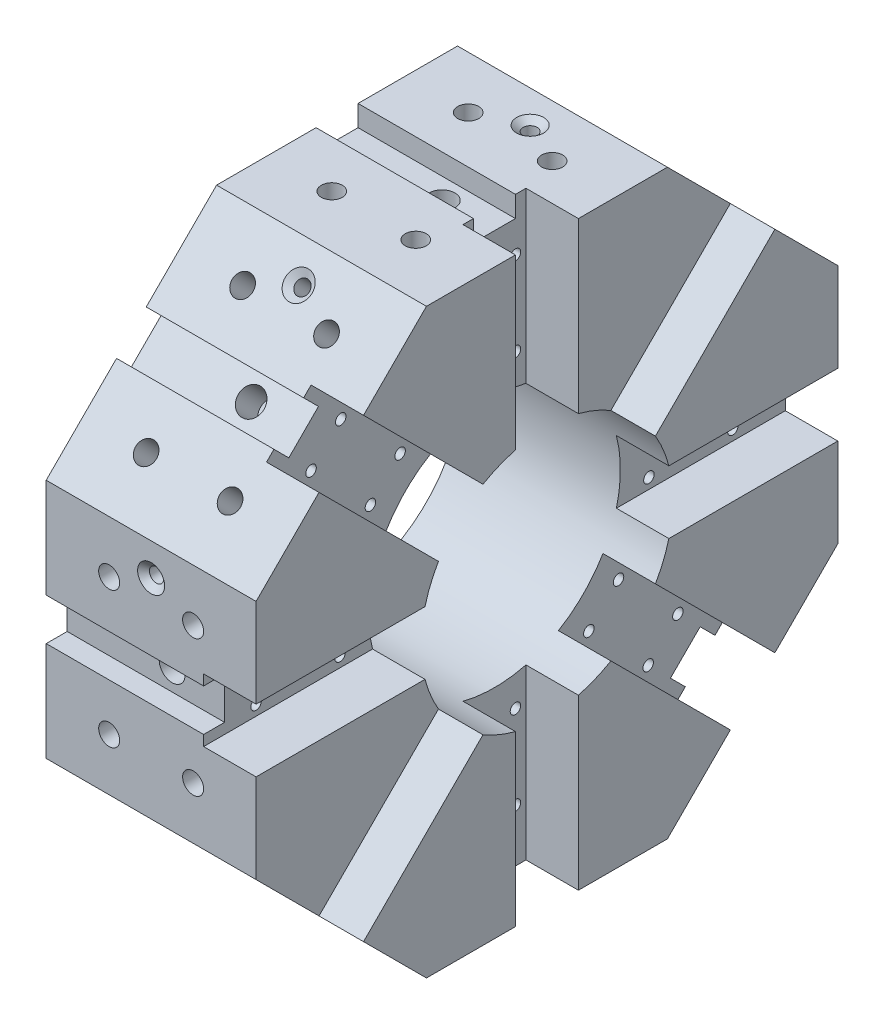
from build123d import *

# Parameters (mm, degrees)
SKETCH_2_R               = 60
EXTRUDE_1_DEPTH          = 100
CUT_EXTRUDE_START        = -80.48718
SKETCH_4_W               = 25
SKETCH_4_H               = 30
CUT_EXTRUDE_1_DEPTH      = 80.48718
SKETCH_6_W               = 20
SKETCH_6_H               = 10
CUT_EXTRUDE_2_DEPTH      = 75
SKETCH_7_R               = 5
CUT_EXTRUDE_3_DEPTH      = 20
SKETCH_10_R              = 2.5
CUT_EXTRUDE_4_DEPTH      = 10
PATTERN_CIRCULAR_1_COUNT = 8


with BuildPart() as part:
    # 草图2 → 凸台-拉伸1 (new body)
    with BuildSketch(Plane(origin=(0, 0, 0), x_dir=(0, 0, -1), z_dir=(1, 0, 0))):
        Polygon((-57.402514855, 138.581929877), (-138.581929877, 57.402514855), (-138.581929877, -57.402514855), (-57.402514855, -138.581929877), (57.402514855, -138.581929877), (138.581929877, -57.402514855), (138.581929877, 57.402514855), (57.402514855, 138.581929877), align=None)
        Circle(SKETCH_2_R, mode=Mode.SUBTRACT)
    extrude(amount=EXTRUDE_1_DEPTH)

    # 草图4 → 切除-拉伸1 (cut)
    with BuildSketch(Plane(origin=(0, 138.581929877, 0), x_dir=(1, 0, 0), z_dir=(0, 1, 0)).offset(CUT_EXTRUDE_START)):
        with Locations((87.5, 0)):
            Rectangle(SKETCH_4_W, SKETCH_4_H)
    cut_extrude_1 = extrude(amount=CUT_EXTRUDE_1_DEPTH, mode=Mode.SUBTRACT)

    # 草图6 → 切除-拉伸2 (cut)
    with BuildSketch(Plane(origin=(75, 0, 0), x_dir=(0, 0, -1), z_dir=(1, 0, 0))):
        with Locations((0, 133.581929877)):
            Rectangle(SKETCH_6_W, SKETCH_6_H)
    cut_extrude_2 = extrude(amount=-CUT_EXTRUDE_2_DEPTH, mode=Mode.SUBTRACT)

    # 草图7 → 切除-拉伸3 (cut)
    with BuildSketch(Plane(origin=(0, 138.581929877, 0), x_dir=(1, 0, 0), z_dir=(0, 1, 0))):
        with Locations((30, 32.5)):
            Circle(SKETCH_7_R)
        with Locations((70, 32.5)):
            Circle(SKETCH_7_R)
        with Locations((30, -32.5)):
            Circle(SKETCH_7_R)
        with Locations((70, -32.5)):
            Circle(SKETCH_7_R)
    cut_extrude_3 = extrude(amount=-CUT_EXTRUDE_3_DEPTH, mode=Mode.SUBTRACT)

    # 草图8 → 9/16-12 螺纹孔1 (revolve, cut)
    with BuildSketch(Plane(origin=(50, 128.581929877, 0), x_dir=(0, 0, 1), z_dir=(1, 0, 0))):
        Polygon((0, 0), (0, 18.551789574), (6.15188, 15), (6.15188, 0), align=None)
    hole_wizard_9_16_12_1 = revolve(axis=Axis((50, 134.931929877, 0), (0, -1, 0)), mode=Mode.SUBTRACT)

    # 草图10 → 切除-拉伸4 (cut)
    with BuildSketch(Plane(origin=(75, 0, 0), x_dir=(0, 0, -1), z_dir=(1, 0, 0))):
        with Locations((-10, 113.581929877)):
            Circle(SKETCH_10_R)
        with Locations((10, 113.581929877)):
            Circle(SKETCH_10_R)
        with Locations((10, 73.581929877)):
            Circle(SKETCH_10_R)
        with Locations((-10, 73.581929877)):
            Circle(SKETCH_10_R)
    cut_extrude_4 = extrude(amount=-CUT_EXTRUDE_4_DEPTH, mode=Mode.SUBTRACT)

    # 草图13 → 1/4 平头机械螺钉的锥形沉头孔 (100)1 (revolve, cut)
    with BuildSketch(Plane(origin=(50, 138.581929877, -42), x_dir=(0, 0, 1), z_dir=(1, 0, 0))):
        Polygon((0, 0), (0, 22.029827343), (3.3782, 20), (3.3782, 2.568232241), (6.4389, 0), align=None)
    hole_wizard_1_4_100_1 = revolve(axis=Axis((50, 144.931929877, -42), (0, -1, 0)), mode=Mode.SUBTRACT)

    # 阵列(圆周)1: 切除-拉伸1, 切除-拉伸2, 切除-拉伸3, 9/16-12 螺纹孔1, 切除-拉伸4, 1/4 平头机械螺钉的锥形沉头孔 (100)1 ×8 about axis
    pattern_circular_1_axis = Axis((0, 0, 0), (1, 0, 0))
    for i in range(1, PATTERN_CIRCULAR_1_COUNT):
        add(cut_extrude_1.rotate(pattern_circular_1_axis, i * 360 / PATTERN_CIRCULAR_1_COUNT), mode=Mode.SUBTRACT)
        add(cut_extrude_2.rotate(pattern_circular_1_axis, i * 360 / PATTERN_CIRCULAR_1_COUNT), mode=Mode.SUBTRACT)
        add(cut_extrude_3.rotate(pattern_circular_1_axis, i * 360 / PATTERN_CIRCULAR_1_COUNT), mode=Mode.SUBTRACT)
        add(hole_wizard_9_16_12_1.rotate(pattern_circular_1_axis, i * 360 / PATTERN_CIRCULAR_1_COUNT), mode=Mode.SUBTRACT)
        add(cut_extrude_4.rotate(pattern_circular_1_axis, i * 360 / PATTERN_CIRCULAR_1_COUNT), mode=Mode.SUBTRACT)
        add(hole_wizard_1_4_100_1.rotate(pattern_circular_1_axis, i * 360 / PATTERN_CIRCULAR_1_COUNT), mode=Mode.SUBTRACT)


solid = part.part
